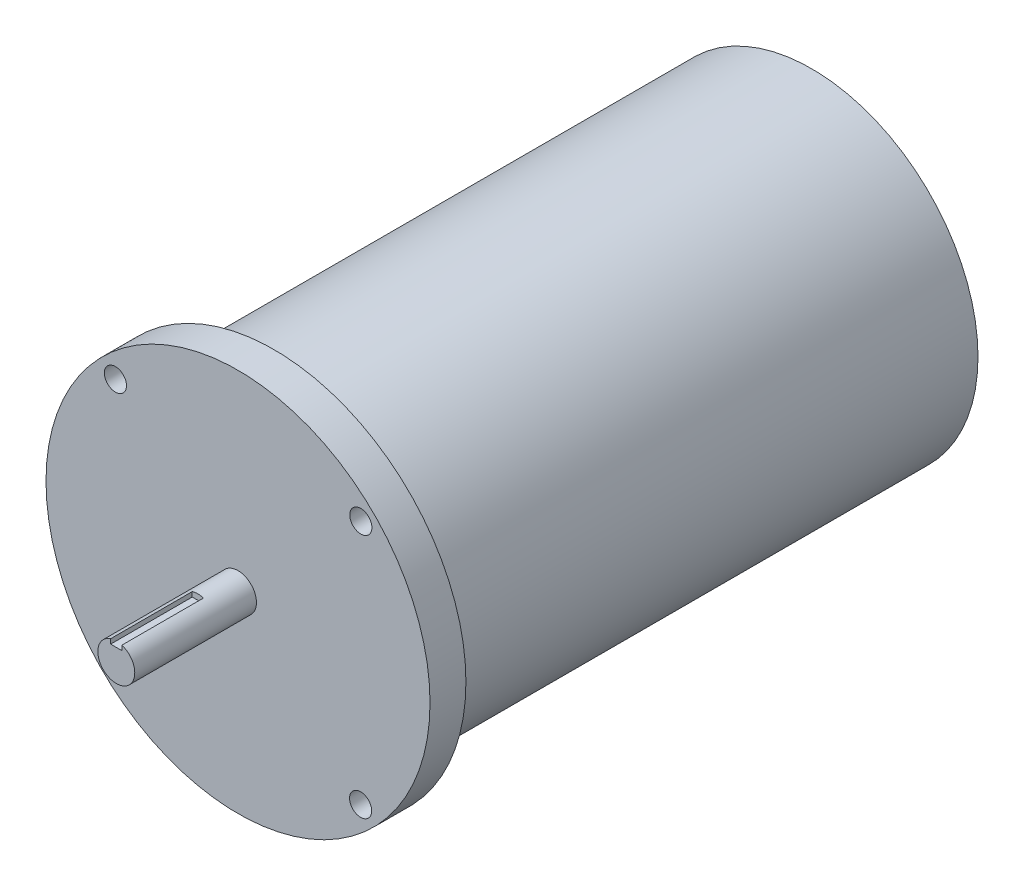
from build123d import *

# Parameters (mm, degrees)
SKETCH2_R           = 71.501
BOSS_EXTRUDE1_DEPTH = 231.199972222
SKETCH3_R           = 82.55
SKETCH3_R_2         = 4.7625
BOSS_EXTRUDE2_DEPTH = 15.434027778
SKETCH4_R           = 7.9375
BOSS_EXTRUDE3_DEPTH = 52.324
SKETCH5_W           = 4.826
SKETCH5_H           = 4.826
CUT_EXTRUDE1_DEPTH  = 35.052


with BuildPart() as part:
    # Sketch2 → Boss-Extrude1 (new body)
    with BuildSketch(Plane.XY):
        Circle(SKETCH2_R)
    extrude(amount=BOSS_EXTRUDE1_DEPTH)

    # Sketch3 → Boss-Extrude2 (add)
    with BuildSketch(Plane.XY.offset(231.199972222)):
        Circle(SKETCH3_R)
        with Locations((-52.714065184, 52.803905992)):
            Circle(SKETCH3_R_2, mode=Mode.SUBTRACT)
        with Locations((52.803905992, 52.714065184)):
            Circle(SKETCH3_R_2, mode=Mode.SUBTRACT)
        with Locations((52.714065184, -52.803905992)):
            Circle(SKETCH3_R_2, mode=Mode.SUBTRACT)
        with Locations((-52.803905992, -52.714065184)):
            Circle(SKETCH3_R_2, mode=Mode.SUBTRACT)
    extrude(amount=BOSS_EXTRUDE2_DEPTH)

    # Sketch4 → Boss-Extrude3 (add)
    with BuildSketch(Plane.XY.offset(246.634)):
        Circle(SKETCH4_R)
    extrude(amount=BOSS_EXTRUDE3_DEPTH)

    # Sketch5 → Cut-Extrude1 (cut)
    with BuildSketch(Plane.XY.offset(298.958)):
        with Locations((0, 7.9375)):
            Rectangle(SKETCH5_W, SKETCH5_H)
    extrude(amount=-CUT_EXTRUDE1_DEPTH, mode=Mode.SUBTRACT)


solid = part.part
